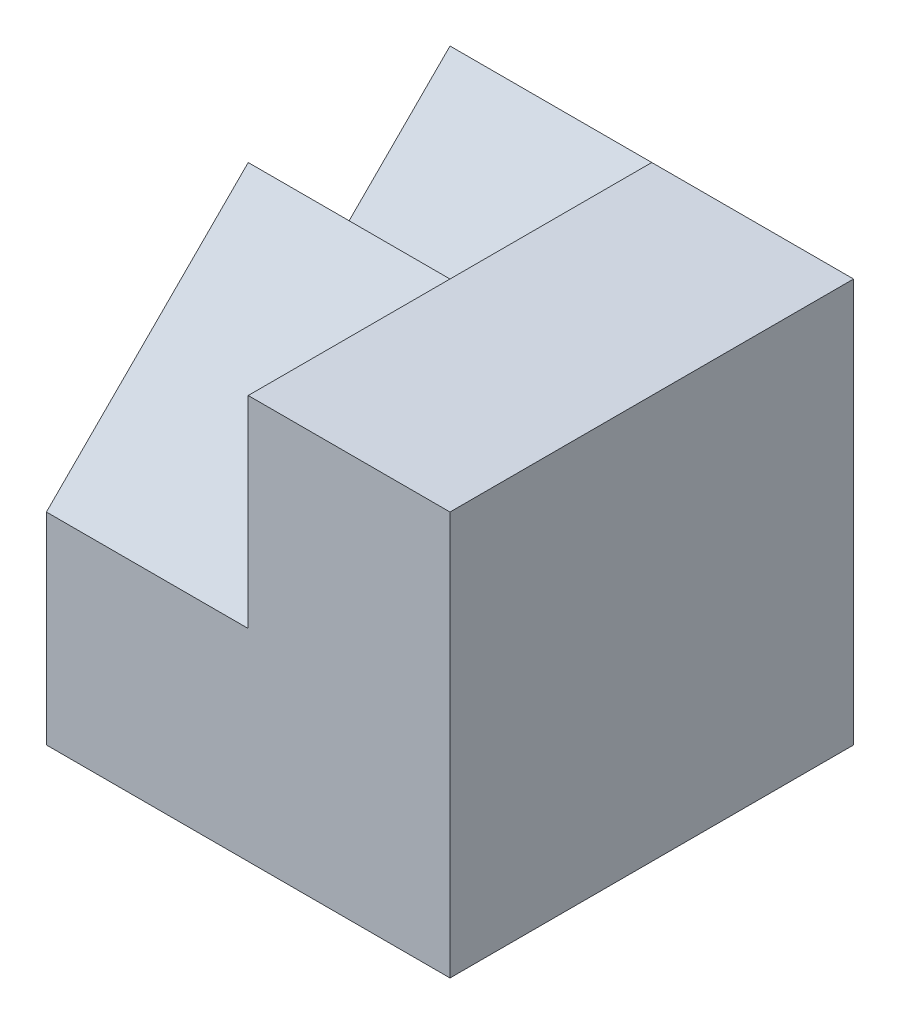
from build123d import *

# Parameters (mm, degrees)
SKETCH1_W           = 4
SKETCH1_H           = 4
BOSS_EXTRUDE1_DEPTH = 4
CUT_EXTRUDE1_DEPTH  = 2


with BuildPart() as part:
    # Sketch1 → Boss-Extrude1 (new body)
    with BuildSketch(Plane(origin=(0, 0, 0), x_dir=(1, 0, 0), z_dir=(0, 1, 0))):
        Rectangle(SKETCH1_W, SKETCH1_H)
    extrude(amount=BOSS_EXTRUDE1_DEPTH)

    # Sketch2 → Cut-Extrude1 (cut)
    with BuildSketch(Plane.ZY.offset(2)):
        Polygon((0, 2), (0, 4), (-2, 4), align=None)
        Polygon((0, 4), (2, 2), (2, 4), align=None)
    extrude(amount=-CUT_EXTRUDE1_DEPTH, mode=Mode.SUBTRACT)


solid = part.part
